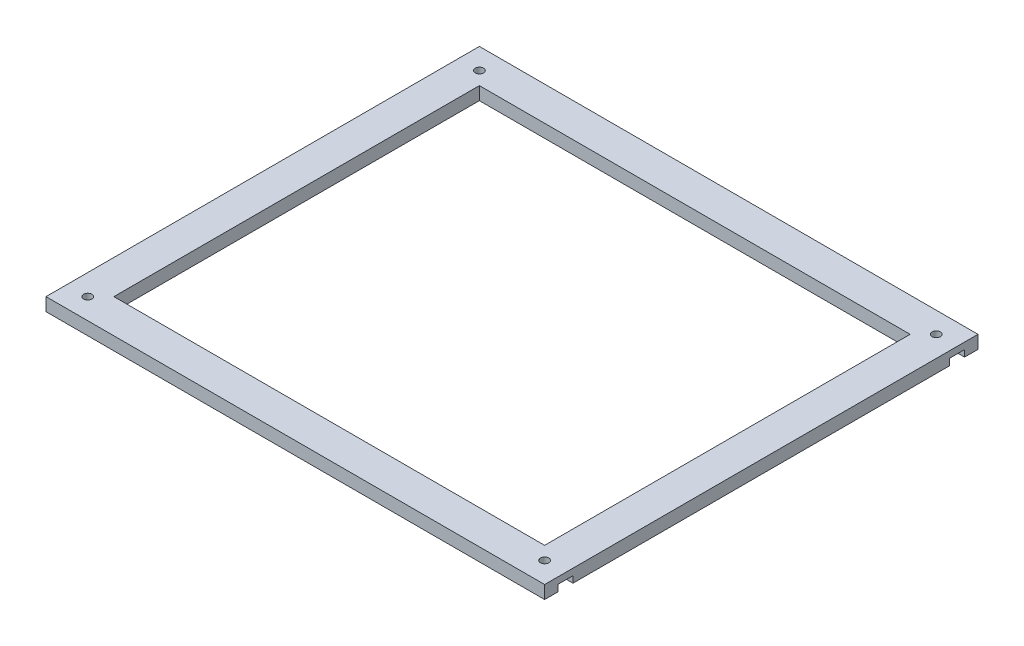
from build123d import *

# Parameters (mm, degrees)
SKETCH2_W           = 165
SKETCH2_H           = 140
BOSS_EXTRUDE1_DEPTH = 5
SKETCH2_3_R         = 1.6
BOSS_EXTRUDE2_DEPTH = 2.5


with BuildPart() as part:
    # Sketch2 → Boss-Extrude1 (new body)
    with BuildSketch(Plane(origin=(0, 0, 0), x_dir=(1, 0, 0), z_dir=(0, 1, 0))):
        Polygon((-95.5, -77.85), (-95.5, -83), (95.5, -83), (95.5, -77.85), (85.854551733, -77.85), (84.209103466, -75), (85.854551733, -72.15), (95.5, -72.15), (95.5, 72.15), (85.854551733, 72.15), (84.209103466, 75), (85.854551733, 77.85), (95.5, 77.85), (95.5, 83), (-95.5, 83), (-95.5, 77.85), (-85.854551733, 77.85), (-84.209103466, 75), (-85.854551733, 72.15), (-95.5, 72.15), (-95.5, -72.15), (-85.854551733, -72.15), (-84.209103466, -75), (-85.854551733, -77.85), align=None)
        Rectangle(SKETCH2_W, SKETCH2_H, mode=Mode.SUBTRACT)
    extrude(amount=-BOSS_EXTRUDE1_DEPTH)

    # Sketch2_3 → Boss-Extrude2 (add)
    # profile 1 of 4: a face of its own
    with BuildSketch(Plane(origin=(0, 0, 0), x_dir=(1, 0, 0), z_dir=(0, 1, 0))):
        Polygon((-95.5, -77.85), (-85.854551733, -77.85), (-84.209103466, -75), (-85.854551733, -72.15), (-95.5, -72.15), align=None)
        with Locations((-87.5, -75)):
            Circle(SKETCH2_3_R, mode=Mode.SUBTRACT)
    # profile 2 of 4: a face of its own
    with BuildSketch(Plane(origin=(0, 0, 0), x_dir=(1, 0, 0), z_dir=(0, 1, 0))):
        Polygon((95.5, -77.85), (95.5, -72.15), (85.854551733, -72.15), (84.209103466, -75), (85.854551733, -77.85), align=None)
        with Locations((87.5, -75)):
            Circle(SKETCH2_3_R, mode=Mode.SUBTRACT)
    # profile 3 of 4: a face of its own
    with BuildSketch(Plane(origin=(0, 0, 0), x_dir=(1, 0, 0), z_dir=(0, 1, 0))):
        Polygon((-95.5, 72.15), (-85.854551733, 72.15), (-84.209103466, 75), (-85.854551733, 77.85), (-95.5, 77.85), align=None)
        with Locations((-87.5, 75)):
            Circle(SKETCH2_3_R, mode=Mode.SUBTRACT)
    # profile 4 of 4: a face of its own
    with BuildSketch(Plane(origin=(0, 0, 0), x_dir=(1, 0, 0), z_dir=(0, 1, 0))):
        Polygon((95.5, 72.15), (95.5, 77.85), (85.854551733, 77.85), (84.209103466, 75), (85.854551733, 72.15), align=None)
        with Locations((87.5, 75)):
            Circle(SKETCH2_3_R, mode=Mode.SUBTRACT)
    extrude(amount=-BOSS_EXTRUDE2_DEPTH)


solid = part.part
